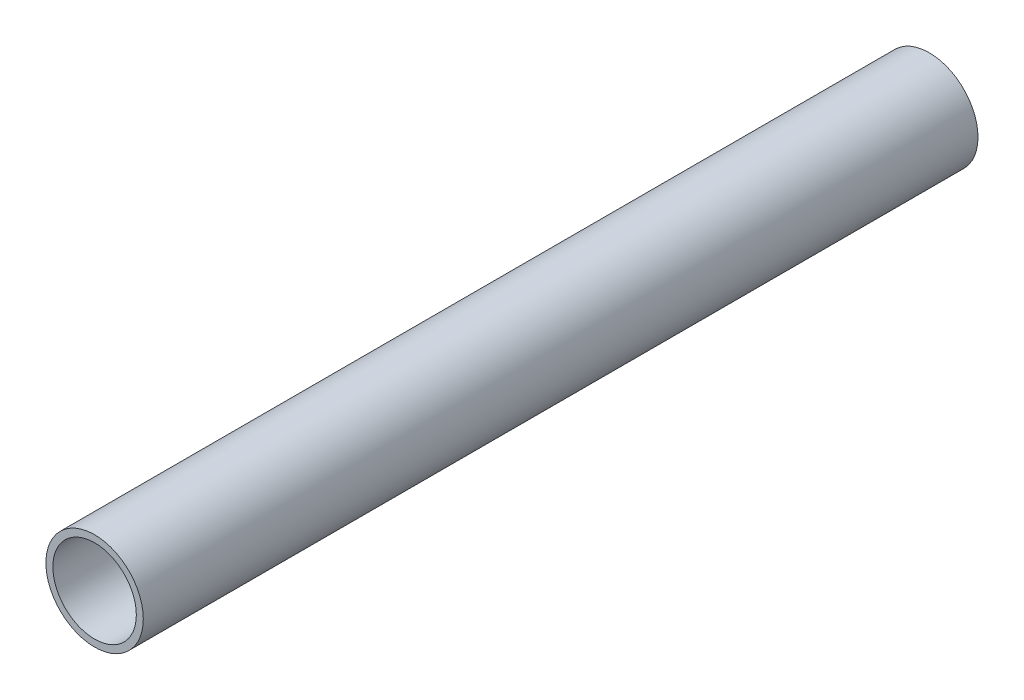
from build123d import *

# Parameters (mm, degrees)
SKETCH1_R           = 11.1125
SKETCH1_R_2         = 9.525
BOSS_EXTRUDE1_DEPTH = 95.25


with BuildPart() as part:
    # Sketch1 → Boss-Extrude1 (new body, symmetric)
    with BuildSketch(Plane.XY):
        Circle(SKETCH1_R)
        Circle(SKETCH1_R_2, mode=Mode.SUBTRACT)
    extrude(amount=BOSS_EXTRUDE1_DEPTH, both=True)


solid = part.part
